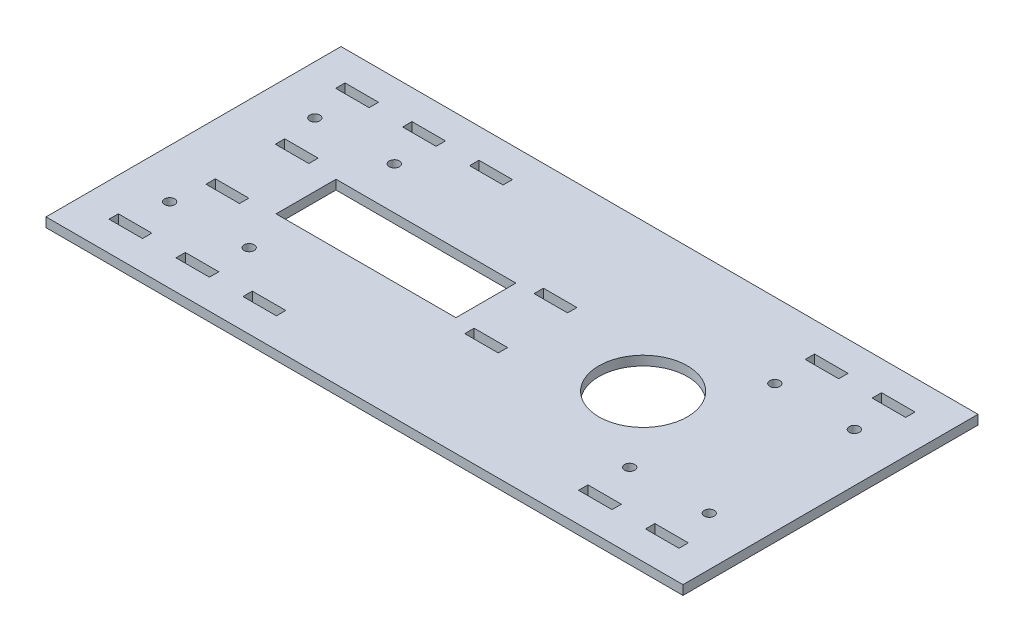
from build123d import *

# Parameters (mm, degrees)
SKETCH1_W               = 215.9
SKETCH1_H               = 100
BOSS_EXTRUDE1_DEPTH     = 3.175
SKETCH3_W               = 11.35
SKETCH3_H               = 3.175
CUT_EXTRUDE2_DEPTH      = 3.175
SKETCH4_W               = 11.35
SKETCH4_H               = 3.175
CUT_EXTRUDE3_DEPTH      = 3.175
SKETCH5_W               = 60.96
SKETCH5_H               = 20.32
CUT_EXTRUDE4_DEPTH      = 1
CUT_EXTRUDE4_DEPTH_BACK = 3.175
SKETCH6_R               = 1.7145
CUT_EXTRUDE5_DEPTH      = 3.175
SKETCH7_R               = 15
CUT_EXTRUDE6_DEPTH      = 3.175
SKETCH8_W               = 11.35
SKETCH8_H               = 3.175
CUT_EXTRUDE7_DEPTH      = 3.175


with BuildPart() as part:
    # Sketch1 → Boss-Extrude1 (new body)
    with BuildSketch(Plane(origin=(0, 0, 0), x_dir=(1, 0, 0), z_dir=(0, 1, 0))):
        with Locations((-1.255776173, 17.463898917)):
            Rectangle(SKETCH1_W, SKETCH1_H)
    extrude(amount=BOSS_EXTRUDE1_DEPTH)

    # Sketch3 → Cut-Extrude2 (cut)
    with BuildSketch(Plane(origin=(0, 3.175, 0), x_dir=(1, 0, 0), z_dir=(0, 1, 0))):
        with Locations((-92.180776173, 55.876398917)):
            Rectangle(SKETCH3_W, SKETCH3_H)
        with Locations((-46.780776173, 55.876398917)):
            Rectangle(SKETCH3_W, SKETCH3_H)
        with Locations((-69.480776173, 55.876398917)):
            Rectangle(SKETCH3_W, SKETCH3_H)
        with Locations((66.969233827, 55.876398917)):
            Rectangle(SKETCH3_W, SKETCH3_H)
        with Locations((89.669223827, 55.876398917)):
            Rectangle(SKETCH3_W, SKETCH3_H)
    extrude(amount=-CUT_EXTRUDE2_DEPTH, mode=Mode.SUBTRACT)

    # Sketch4 → Cut-Extrude3 (cut)
    with BuildSketch(Plane(origin=(0, 3.175, 0), x_dir=(1, 0, 0), z_dir=(0, 1, 0))):
        with Locations((-92.180776173, -20.948601083)):
            Rectangle(SKETCH4_W, SKETCH4_H)
        with Locations((-69.480776173, -20.948601083)):
            Rectangle(SKETCH4_W, SKETCH4_H)
        with Locations((-46.780776173, -20.948601083)):
            Rectangle(SKETCH4_W, SKETCH4_H)
        with Locations((66.969233827, -20.948601083)):
            Rectangle(SKETCH4_W, SKETCH4_H)
        with Locations((89.669223827, -20.948601083)):
            Rectangle(SKETCH4_W, SKETCH4_H)
    extrude(amount=-CUT_EXTRUDE3_DEPTH, mode=Mode.SUBTRACT)

    # Sketch5 → Cut-Extrude4 (cut, two sides)
    with BuildSketch(Plane(origin=(0, 3.175, 0), x_dir=(1, 0, 0), z_dir=(0, 1, 0))) as cut_extrude4_sk:
        with Locations((-40.625776173, 17.503898917)):
            Rectangle(SKETCH5_W, SKETCH5_H)
    extrude(amount=CUT_EXTRUDE4_DEPTH, mode=Mode.SUBTRACT)
    extrude(cut_extrude4_sk.sketch, amount=-CUT_EXTRUDE4_DEPTH_BACK, mode=Mode.SUBTRACT)

    # Sketch6 → Cut-Extrude5 (cut)
    with BuildSketch(Plane(origin=(0, 3.175, 0), x_dir=(1, 0, 0), z_dir=(0, 1, 0))):
        with Locations((-92.695776173, 42.063898917)):
            Circle(SKETCH6_R)
        with Locations((-65.746376173, 42.063898917)):
            Circle(SKETCH6_R)
        with Locations((-92.695776173, -7.136101083)):
            Circle(SKETCH6_R)
        with Locations((-65.746376173, -7.136101083)):
            Circle(SKETCH6_R)
        with Locations((63.234823827, 42.063898917)):
            Circle(SKETCH6_R)
        with Locations((90.184223827, 42.063898917)):
            Circle(SKETCH6_R)
        with Locations((63.234823827, -7.136101083)):
            Circle(SKETCH6_R)
        with Locations((90.184223827, -7.136101083)):
            Circle(SKETCH6_R)
    extrude(amount=-CUT_EXTRUDE5_DEPTH, mode=Mode.SUBTRACT)

    # Sketch7 → Cut-Extrude6 (cut)
    with BuildSketch(Plane(origin=(0, 3.175, 0), x_dir=(1, 0, 0), z_dir=(0, 1, 0))):
        with Locations((43.194223827, 17.463898917)):
            Circle(SKETCH7_R)
    extrude(amount=-CUT_EXTRUDE6_DEPTH, mode=Mode.SUBTRACT)

    # Sketch8 → Cut-Extrude7 (cut)
    with BuildSketch(Plane(origin=(0, 3.175, 0), x_dir=(1, 0, 0), z_dir=(0, 1, 0))):
        with Locations((-86.004776173, 5.756398917)):
            Rectangle(SKETCH8_W, SKETCH8_H)
        with Locations((-86.004776173, 29.251398917)):
            Rectangle(SKETCH8_W, SKETCH8_H)
        with Locations((1.705223827, 5.756398917)):
            Rectangle(SKETCH8_W, SKETCH8_H)
        with Locations((1.705223827, 29.251398917)):
            Rectangle(SKETCH8_W, SKETCH8_H)
    extrude(amount=-CUT_EXTRUDE7_DEPTH, mode=Mode.SUBTRACT)


solid = part.part
